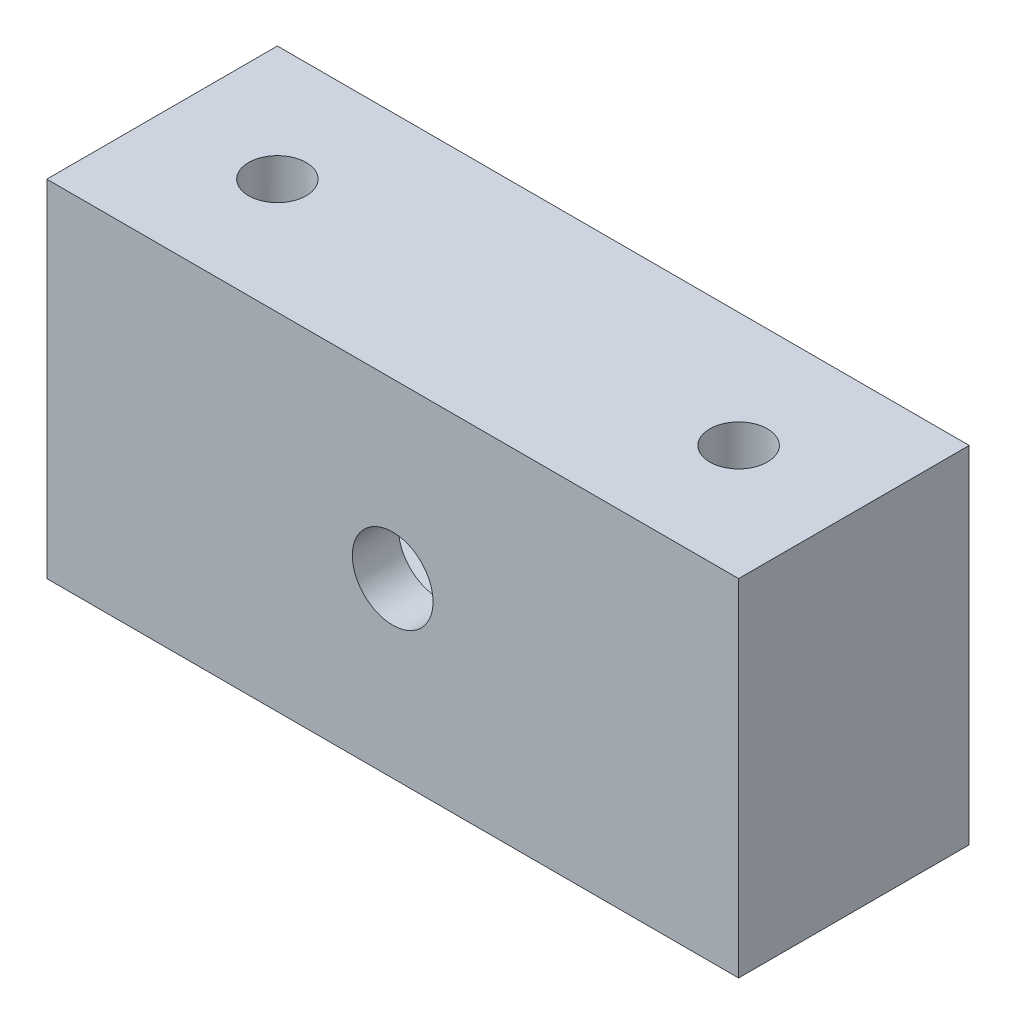
from build123d import *

# Parameters (mm, degrees)
ESQUISSE1_W             = 30
ESQUISSE1_H             = 15
BOSS_EXTRU_1_DEPTH      = 10
ESQUISSE2_W             = 24
ESQUISSE2_H             = 9
ENL_V_MAT_EXTRU_1_DEPTH = 8
CONG_1_R                = 2
ESQUISSE3_R             = 1.75
ENL_V_MAT_EXTRU_2_DEPTH = 3
TROU_TARAUD_M31_D       = 2.5
TROU_TARAUD_M32_D       = 2.5


with BuildPart() as part:
    # Esquisse1 → Boss.-Extru.1 (new body)
    with BuildSketch(Plane.XY):
        Rectangle(ESQUISSE1_W, ESQUISSE1_H)
    extrude(amount=BOSS_EXTRU_1_DEPTH)

    # Esquisse2 → Enlèv. mat.-Extru.1 (cut)
    with BuildSketch(Plane(origin=(0, 0, 0), x_dir=(-1, 0, 0), z_dir=(0, 0, -1))):
        Rectangle(ESQUISSE2_W, ESQUISSE2_H)
    extrude(amount=-ENL_V_MAT_EXTRU_1_DEPTH, mode=Mode.SUBTRACT)

    # Congé1
    cong_1_edges = [part.edges().sort_by_distance(p)[0] for p in [
        (12, -4.5, 4),
        (12, 4.5, 4),
        (-12, 4.5, 4),
        (-12, -4.5, 4),
    ]]
    fillet(cong_1_edges, radius=CONG_1_R)

    # Esquisse3 → Enlèv. mat.-Extru.2 (cut, through all)
    with BuildSketch(Plane(origin=(0, 0, 8), x_dir=(-1, 0, 0), z_dir=(0, 0, -1))):
        Circle(ESQUISSE3_R)
    extrude(amount=-ENL_V_MAT_EXTRU_2_DEPTH, mode=Mode.SUBTRACT)

    # Trou taraudé M31 (through all)
    with Locations(Plane(origin=(0, -7.5, 0), x_dir=(-1, 0, 0), z_dir=(0, -1, 0))):
        with Locations((-10, -5)):
            Hole(TROU_TARAUD_M31_D / 2)

    # Trou taraudé M32 (through all)
    with Locations(Plane(origin=(0, -7.5, 0), x_dir=(-1, 0, 0), z_dir=(0, -1, 0))):
        with Locations((10, -5)):
            Hole(TROU_TARAUD_M32_D / 2)


solid = part.part
